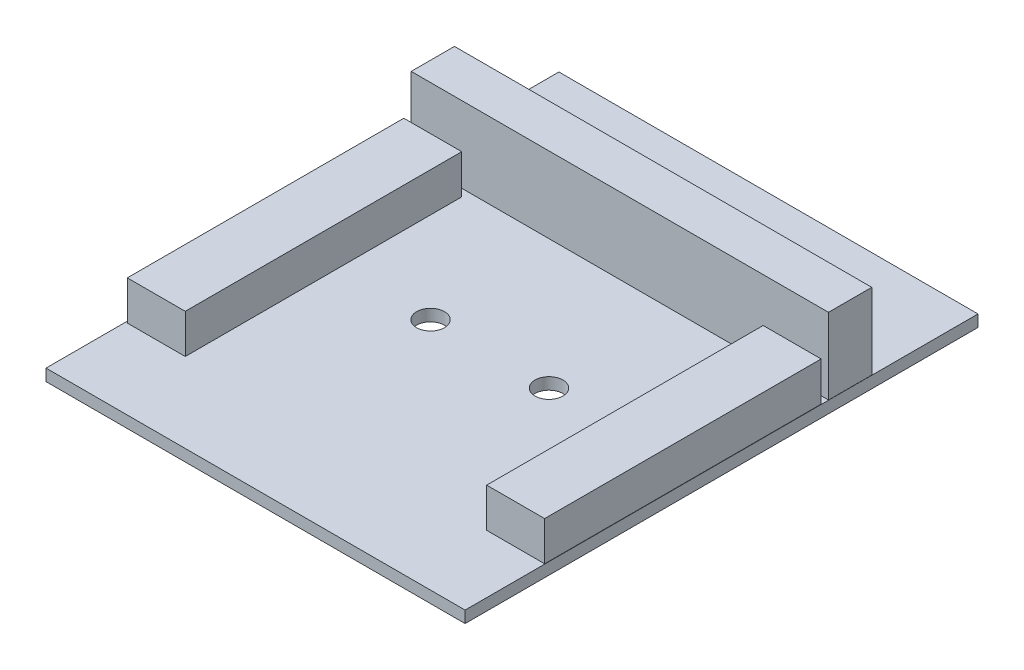
from build123d import *

# Parameters (mm, degrees)
ESQUISSE1_W        = 57.14738142
ESQUISSE1_H        = 69.935606632
ESQUISSE1_R        = 1.9
BOSS_EXTRU_7_DEPTH = 1.6
ESQUISSE6_W        = 7.9
ESQUISSE6_H        = 37.7
BOSS_EXTRU_8_DEPTH = 5.34
ESQUISSE7_W        = 56.9
ESQUISSE7_H        = 5.9
BOSS_EXTRU_9_DEPTH = 10.36


with BuildPart() as part:
    # Esquisse1 → Boss.-Extru.7 (new body)
    with BuildSketch(Plane(origin=(0, 0, 0), x_dir=(1, 0, 0), z_dir=(0, 1, 0))):
        with Locations((28.57369071, 34.967803316)):
            Rectangle(ESQUISSE1_W, ESQUISSE1_H)
        with Locations((20.5, 31.935606632)):
            Circle(ESQUISSE1_R, mode=Mode.SUBTRACT)
        with Locations((36.64738142, 31.935606632)):
            Circle(ESQUISSE1_R, mode=Mode.SUBTRACT)
    extrude(amount=BOSS_EXTRU_7_DEPTH)

    # Esquisse6 → Boss.-Extru.8 (add)
    with BuildSketch(Plane(origin=(0, 1.6, 0), x_dir=(1, 0, 0), z_dir=(0, 1, 0))):
        with Locations((53.155892473, 29.734566664)):
            Rectangle(ESQUISSE6_W, ESQUISSE6_H)
        with Locations((4.178526772, 29.710022265)):
            Rectangle(ESQUISSE6_W, ESQUISSE6_H)
    extrude(amount=BOSS_EXTRU_8_DEPTH)

    # Esquisse7 → Boss.-Extru.9 (add)
    with BuildSketch(Plane(origin=(0, 1.6, 0), x_dir=(1, 0, 0), z_dir=(0, 1, 0))):
        with Locations((28.670599558, 52.525606632)):
            Rectangle(ESQUISSE7_W, ESQUISSE7_H)
    extrude(amount=BOSS_EXTRU_9_DEPTH)


solid = part.part
